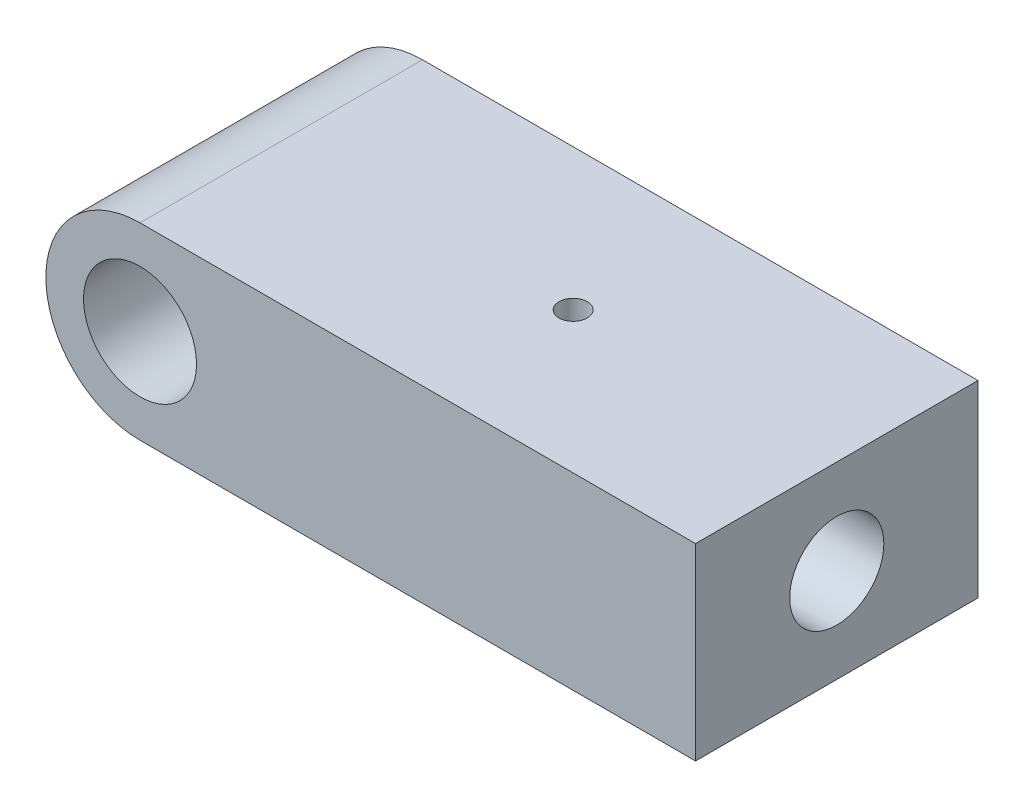
from build123d import *

# Parameters (mm, degrees)
ESQUISSE1_R                         = 6
BOSS_EXTRU_1_DEPTH                  = 15
DIAM_TRE_DU_PER_AGE_10_0_10_1_D     = 10
DIAM_TRE_DU_PER_AGE_10_0_10_1_DEPTH = 40
DIAM_TRE_DU_PER_AGE_3_0_3_1_D       = 3
DIAM_TRE_DU_PER_AGE_3_0_3_1_DEPTH   = 10
DIAM_TRE_DU_PER_AGE_3_0_3_1_TIP     = 0.901290929


with BuildPart() as part:
    # Esquisse1 → Boss.-Extru.1 (new body, symmetric)
    with BuildSketch(Plane.XY):
        with BuildLine():
            Line((0, -10), (59, -10))
            Line((59, -10), (59, 10))
            Line((59, 10), (0, 10))
            ThreePointArc((0, 10), (-10, 0), (0, -10))
        make_face()
        Circle(ESQUISSE1_R, mode=Mode.SUBTRACT)
    extrude(amount=BOSS_EXTRU_1_DEPTH, both=True)

    # Diamètre du perçage Ø10.0 (10)1
    with Locations(Plane(origin=(59, 0, 0), x_dir=(0, 0, -1), z_dir=(1, 0, 0))):
        with Locations((0, 0)):
            Hole(DIAM_TRE_DU_PER_AGE_10_0_10_1_D / 2, depth=DIAM_TRE_DU_PER_AGE_10_0_10_1_DEPTH)

    # Diamètre du perçage Ø3.0 (3)1
    with Locations(Plane(origin=(0, 10, 0), x_dir=(1, 0, 0), z_dir=(0, 1, 0))):
        with Locations((31, 0)):
            Hole(DIAM_TRE_DU_PER_AGE_3_0_3_1_D / 2, depth=DIAM_TRE_DU_PER_AGE_3_0_3_1_DEPTH)
            with Locations((0, 0, -(DIAM_TRE_DU_PER_AGE_3_0_3_1_DEPTH + DIAM_TRE_DU_PER_AGE_3_0_3_1_TIP / 2))):  # 118° drill point
                Cone(0, DIAM_TRE_DU_PER_AGE_3_0_3_1_D / 2, DIAM_TRE_DU_PER_AGE_3_0_3_1_TIP, mode=Mode.SUBTRACT)


solid = part.part
